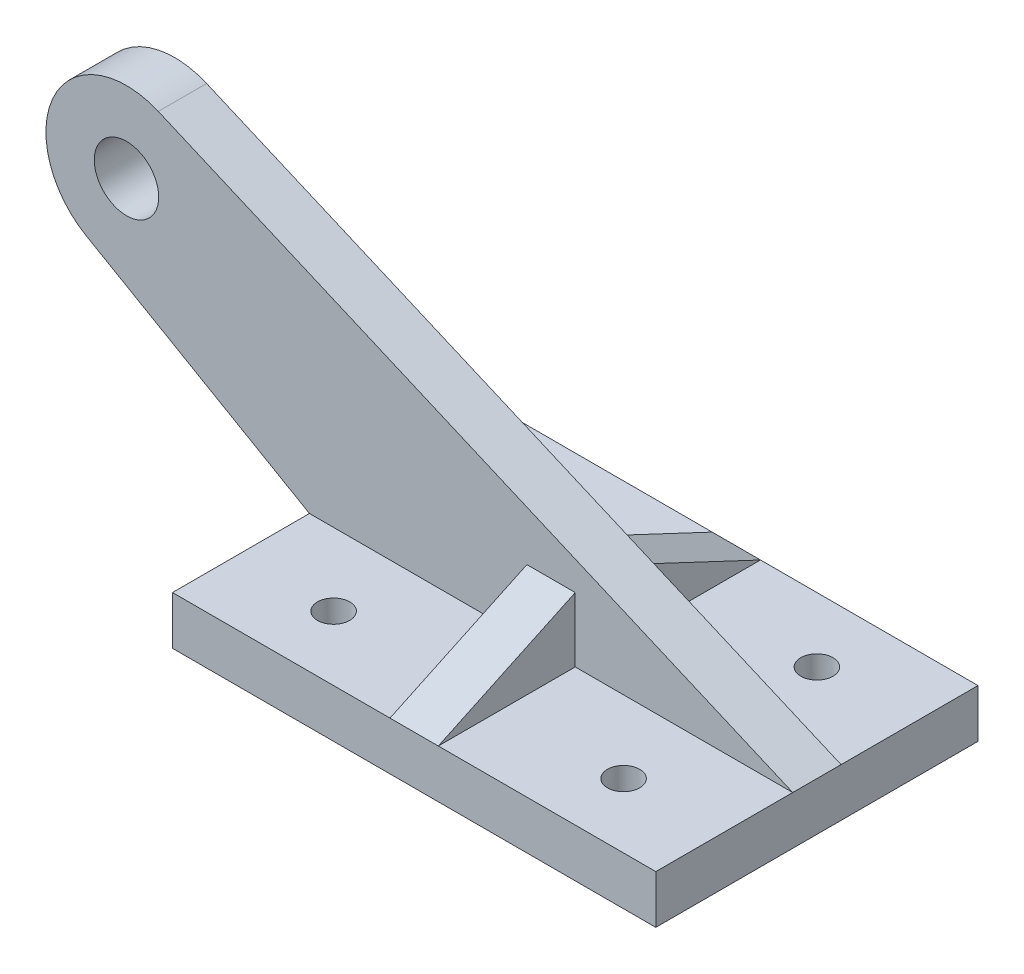
from build123d import *

# Parameters (mm, degrees)
SKETCH1_W           = 150
SKETCH1_H           = 100
BOSS_EXTRUDE1_DEPTH = 15
SKETCH2_R           = 5
CUT_EXTRUDE2_DEPTH  = 15
SKETCH4_R           = 10
BOSS_EXTRUDE3_DEPTH = 7.5
BOSS_EXTRUDE4_DEPTH = 7.5
BOSS_EXTRUDE5_DEPTH = 7.5


with BuildPart() as part:
    # Sketch1 → Boss-Extrude1 (new body)
    with BuildSketch(Plane(origin=(0, 0, 0), x_dir=(1, 0, 0), z_dir=(0, 1, 0))):
        Rectangle(SKETCH1_W, SKETCH1_H)
    extrude(amount=BOSS_EXTRUDE1_DEPTH)

    # Sketch2 → Cut-Extrude2 (cut)
    with BuildSketch(Plane(origin=(0, 15, 0), x_dir=(1, 0, 0), z_dir=(0, 1, 0))):
        with Locations((45, -30)):
            Circle(SKETCH2_R)
        with Locations((45, 30)):
            Circle(SKETCH2_R)
        with Locations((-45, 30)):
            Circle(SKETCH2_R)
        with Locations((-45, -30)):
            Circle(SKETCH2_R)
    extrude(amount=-CUT_EXTRUDE2_DEPTH, mode=Mode.SUBTRACT)

    # Sketch4 → Boss-Extrude3 (add, symmetric)
    with BuildSketch(Plane.XY):
        with BuildLine():
            Line((75, 15), (-75, 15))
            Line((-75, 15), (-144.282032303, 55))
            ThreePointArc((-144.282032303, 55), (-154.13052805, 87.855309915), (-121.911493446, 99.61958071))
            Line((-121.911493446, 99.61958071), (75, 15))
        make_face()
        with Locations((-131.782032303, 76.650635095)):
            Circle(SKETCH4_R, mode=Mode.SUBTRACT)
    extrude(amount=BOSS_EXTRUDE3_DEPTH, both=True)

    # Sketch5 → Boss-Extrude4 (add, symmetric)
    with BuildSketch(Plane(origin=(0, 0, 0), x_dir=(0, 0, -1), z_dir=(1, 0, 0))):
        Polygon((-7.5, 15), (-7.5, 35), (-50, 15), align=None)
    extrude(amount=BOSS_EXTRUDE4_DEPTH, both=True)

    # Sketch6 → Boss-Extrude5 (add, symmetric)
    with BuildSketch(Plane(origin=(0, 0, 0), x_dir=(0, 0, -1), z_dir=(1, 0, 0))):
        Polygon((7.5, 15), (7.5, 35), (50, 15), align=None)
    extrude(amount=BOSS_EXTRUDE5_DEPTH, both=True)


solid = part.part
